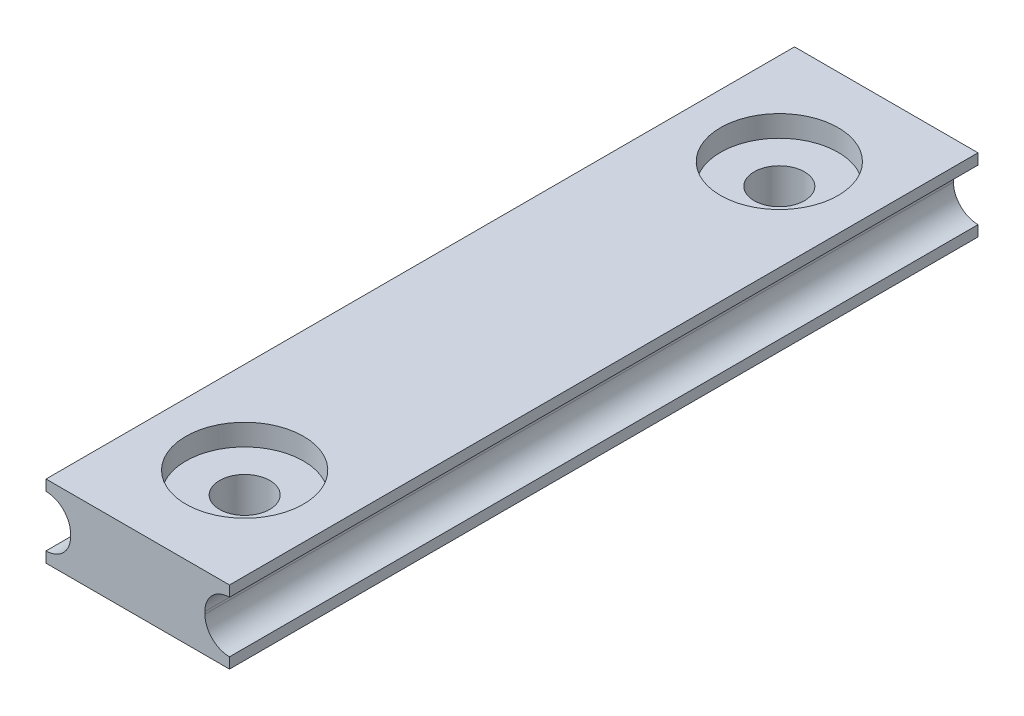
from build123d import *

# Parameters (mm, degrees)
BOSS_EXTRUDE1_DEPTH = 17.5
SKETCH2_R           = 1.175
CUT_EXTRUDE1_DEPTH  = 4.41
SKETCH3_R           = 2.75
CUT_EXTRUDE2_DEPTH  = 1


with BuildPart() as part:
    # Sketch1 → Boss-Extrude1 (new body, symmetric)
    with BuildSketch(Plane.XY):
        with BuildLine():
            Line((-3.14, 0.055), (-3.14, -0.055))
            ThreePointArc((-3.14, -0.055), (-3.476827202, -0.868172798), (-4.29, -1.205))
            Line((-4.29, -1.205), (-4.29, -1.705))
            Line((-4.29, -1.705), (4.29, -1.705))
            Line((4.29, -1.705), (4.29, -1.205))
            ThreePointArc((4.29, -1.205), (3.476827202, -0.868172798), (3.14, -0.055))
            Line((3.14, -0.055), (3.14, 0.055))
            ThreePointArc((3.14, 0.055), (3.476827202, 0.868172798), (4.29, 1.205))
            Line((4.29, 1.205), (4.29, 1.705))
            Line((4.29, 1.705), (-4.29, 1.705))
            Line((-4.29, 1.705), (-4.29, 1.205))
            ThreePointArc((-4.29, 1.205), (-3.476827202, 0.868172798), (-3.14, 0.055))
        make_face()
    extrude(amount=BOSS_EXTRUDE1_DEPTH, both=True)

    # Sketch2 → Cut-Extrude1 (cut, through all)
    with BuildSketch(Plane(origin=(0, 1.705, 0), x_dir=(1, 0, 0), z_dir=(0, 1, 0))):
        with Locations((0, 12.5)):
            Circle(SKETCH2_R)
    cut_extrude1 = extrude(amount=-CUT_EXTRUDE1_DEPTH, mode=Mode.SUBTRACT)

    # Sketch3 → Cut-Extrude2 (cut)
    with BuildSketch(Plane(origin=(0, 1.705, 0), x_dir=(1, 0, 0), z_dir=(0, 1, 0))):
        with Locations((0, 12.5)):
            Circle(SKETCH3_R)
    cut_extrude2 = extrude(amount=-CUT_EXTRUDE2_DEPTH, mode=Mode.SUBTRACT)

    # Mirror1: Cut-Extrude1, Cut-Extrude2 across plane
    add(cut_extrude1.mirror(Plane.XY), mode=Mode.SUBTRACT)
    add(cut_extrude2.mirror(Plane.XY), mode=Mode.SUBTRACT)


solid = part.part
